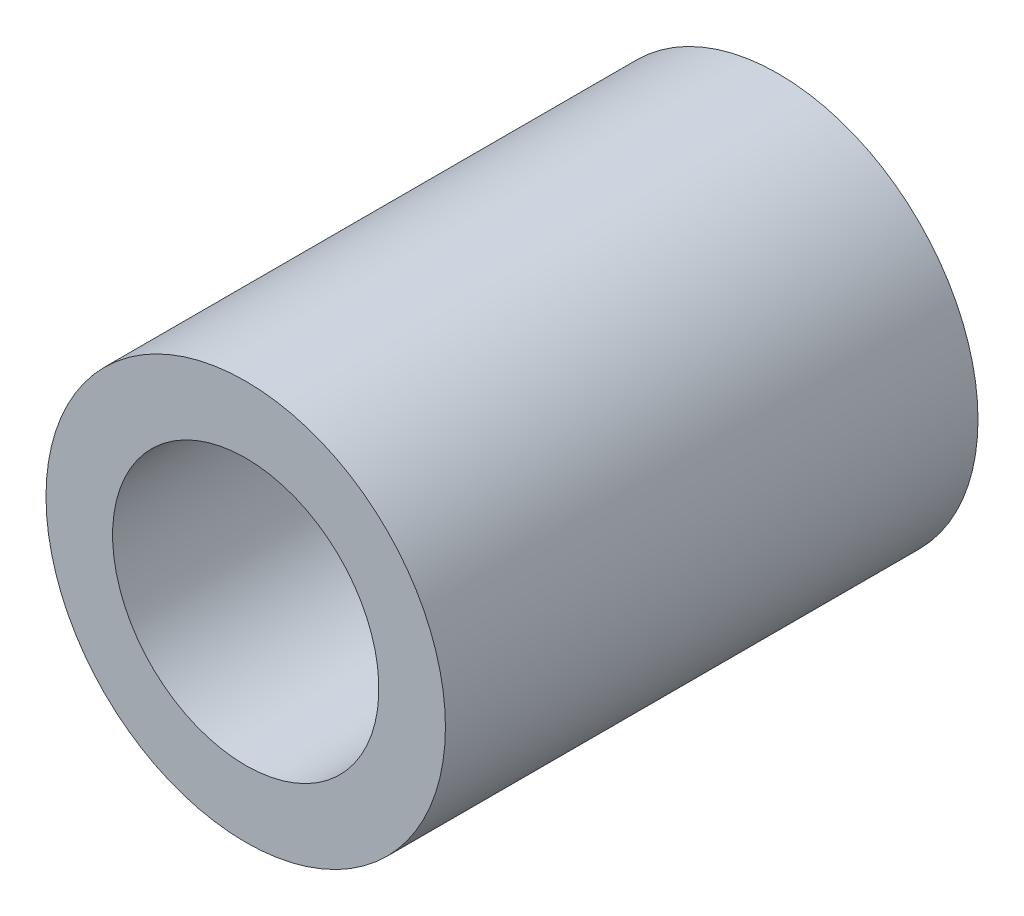
from build123d import *

# Parameters (mm, degrees)
SKETCH1_W = 25.4
SKETCH1_H = 3.175


with BuildPart() as part:
    # Sketch1 → Revolve1 (revolve)
    with BuildSketch(Plane(origin=(0, 0, 0), x_dir=(0, 0, -1), z_dir=(1, 0, 0))):
        with Locations((0, -7.9375)):
            Rectangle(SKETCH1_W, SKETCH1_H)
    revolve(axis=Axis((0, 0, 15.184961871), (0, 0, -1)))


solid = part.part
